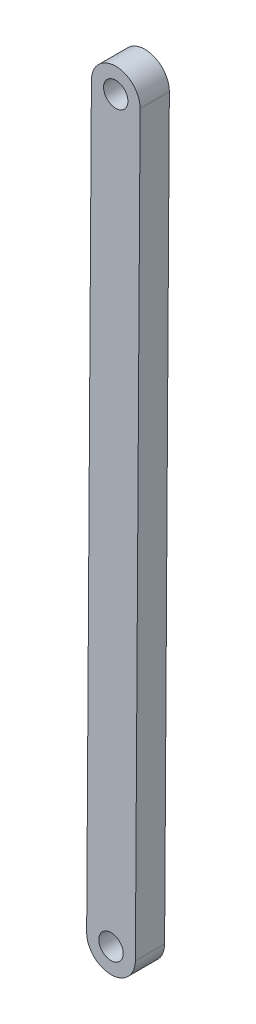
from build123d import *

# Parameters (mm, degrees)
SKETCH1_R           = 5
BOSS_EXTRUDE1_DEPTH = 12


with BuildPart() as part:
    # Sketch1 → Boss-Extrude1 (new body)
    with BuildSketch(Plane.XY):
        with BuildLine():
            Line((9.999794456, -0.064115809), (8.050633785, -304.064115809))
            ThreePointArc((8.050633785, -304.064115809), (-2.013276481, -313.999794456), (-11.948955127, -303.935884191))
            Line((-11.948955127, -303.935884191), (-9.999794456, 0.064115809))
            ThreePointArc((-9.999794456, 0.064115809), (0.064115809, 9.999794456), (9.999794456, -0.064115809))
        make_face()
        with Locations((-1.949160671, -304)):
            Circle(SKETCH1_R, mode=Mode.SUBTRACT)
        Circle(SKETCH1_R, mode=Mode.SUBTRACT)
    extrude(amount=BOSS_EXTRUDE1_DEPTH)


solid = part.part
